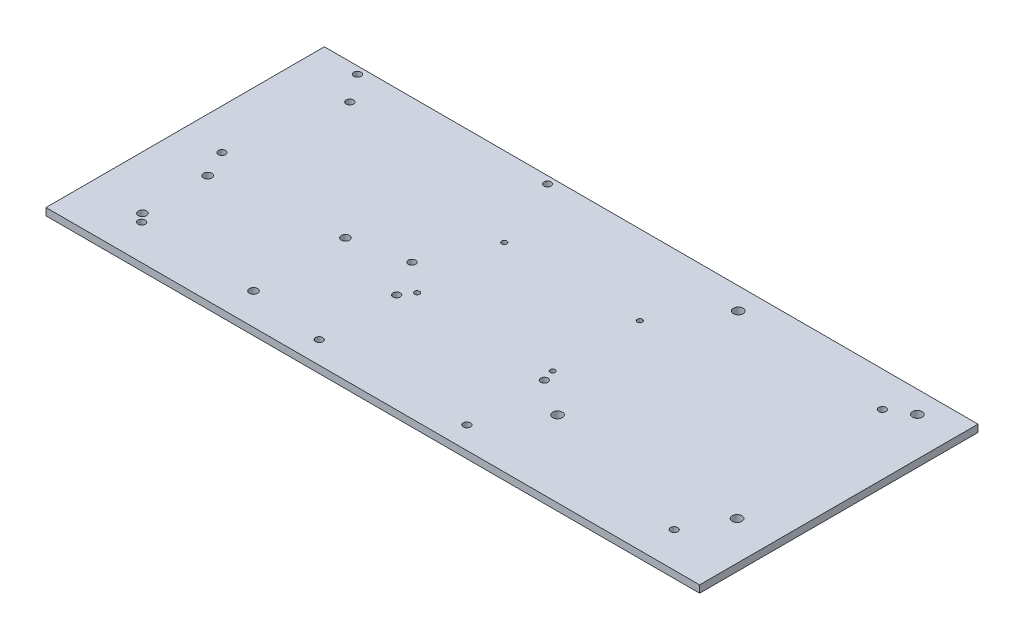
from build123d import *

# Parameters (mm, degrees)
CROQUIS1_W              = 250
CROQUIS1_H              = 115
SALIENTE_EXTRUIR1_DEPTH = 3
CROQUIS3_R              = 1.5
CROQUIS3_R_2            = 2
CROQUIS3_R_3            = 1.05
CROQUIS3_R_4            = 1.7
CORTAR_EXTRUIR1_DEPTH   = 10
CROQUIS4_W              = 115
CROQUIS4_H              = 3
SALIENTE_EXTRUIR2_DEPTH = 10
CROQUIS5_W              = 115
CROQUIS5_H              = 3
SALIENTE_EXTRUIR3_DEPTH = 10
CROQUIS6_R              = 1.5
CORTAR_EXTRUIR2_DEPTH   = 50


with BuildPart() as part:
    # Croquis1 → Saliente-Extruir1 (new body)
    with BuildSketch(Plane(origin=(0, 0, 0), x_dir=(1, 0, 0), z_dir=(0, 1, 0))):
        with Locations((0, 2.5)):
            Rectangle(CROQUIS1_W, CROQUIS1_H)
    extrude(amount=SALIENTE_EXTRUIR1_DEPTH)

    # Croquis3 → Cortar-Extruir1 (cut)
    with BuildSketch(Plane(origin=(0, 3, 0), x_dir=(1, 0, 0), z_dir=(0, 1, 0))):
        with Locations((-39.831376222, 1)):
            Circle(CROQUIS3_R)
        with Locations((-118.331376222, 1)):
            Circle(CROQUIS3_R)
        with Locations((-118.331376222, 57)):
            Circle(CROQUIS3_R)
        with Locations((-39.831376222, 57)):
            Circle(CROQUIS3_R)
        with Locations((45, 50.966241886)):
            Circle(CROQUIS3_R_2)
        with Locations((119, 50.966241886)):
            Circle(CROQUIS3_R_2)
        with Locations((44.851219877, -23.533758114)):
            Circle(CROQUIS3_R_2)
        with Locations((119, -23.533758114)):
            Circle(CROQUIS3_R_2)
        with Locations((-31.3, -13.846238612)):
            Circle(CROQUIS3_R)
        with Locations((-31.3, -45.846238612)):
            Circle(CROQUIS3_R)
        with Locations((29.7, -45.846238612)):
            Circle(CROQUIS3_R)
        with Locations((29.7, -13.846238612)):
            Circle(CROQUIS3_R)
        with Locations((-27.849623113, 27.153761388)):
            Circle(CROQUIS3_R_3)
        with Locations((-27.849623113, -8.846238612)):
            Circle(CROQUIS3_R_3)
        with Locations((28.150376887, -8.846238612)):
            Circle(CROQUIS3_R_3)
        with Locations((28.150376887, 27.153761388)):
            Circle(CROQUIS3_R_3)
        with Locations((-113, -10.2)):
            Circle(CROQUIS3_R_4)
        with Locations((-113, -37.16)):
            Circle(CROQUIS3_R_4)
        with Locations((-62.3, -4)):
            Circle(CROQUIS3_R_4)
        with Locations((-62.3, -42)):
            Circle(CROQUIS3_R_4)
    extrude(amount=-CORTAR_EXTRUIR1_DEPTH, mode=Mode.SUBTRACT)

    # Croquis4 → Saliente-Extruir2 (add)
    with BuildSketch(Plane.ZY.offset(125)):
        with Locations((-2.5, 1.5)):
            Rectangle(CROQUIS4_W, CROQUIS4_H)
    extrude(amount=SALIENTE_EXTRUIR2_DEPTH)

    # Croquis5 → Saliente-Extruir3 (add)
    with BuildSketch(Plane(origin=(125, 0, 0), x_dir=(0, 0, -1), z_dir=(1, 0, 0))):
        with Locations((2.5, 1.5)):
            Rectangle(CROQUIS5_W, CROQUIS5_H)
    extrude(amount=SALIENTE_EXTRUIR3_DEPTH)

    # Croquis6 → Cortar-Extruir2 (cut)
    with BuildSketch(Plane(origin=(0, 3, 0), x_dir=(1, 0, 0), z_dir=(0, 1, 0))):
        with Locations((-110, 45.495168371)):
            Circle(CROQUIS6_R)
        with Locations((-110, -40.5)):
            Circle(CROQUIS6_R)
        with Locations((110, 45.495168371)):
            Circle(CROQUIS6_R)
        with Locations((110, -40.5)):
            Circle(CROQUIS6_R)
    extrude(amount=-CORTAR_EXTRUIR2_DEPTH, mode=Mode.SUBTRACT)


solid = part.part
